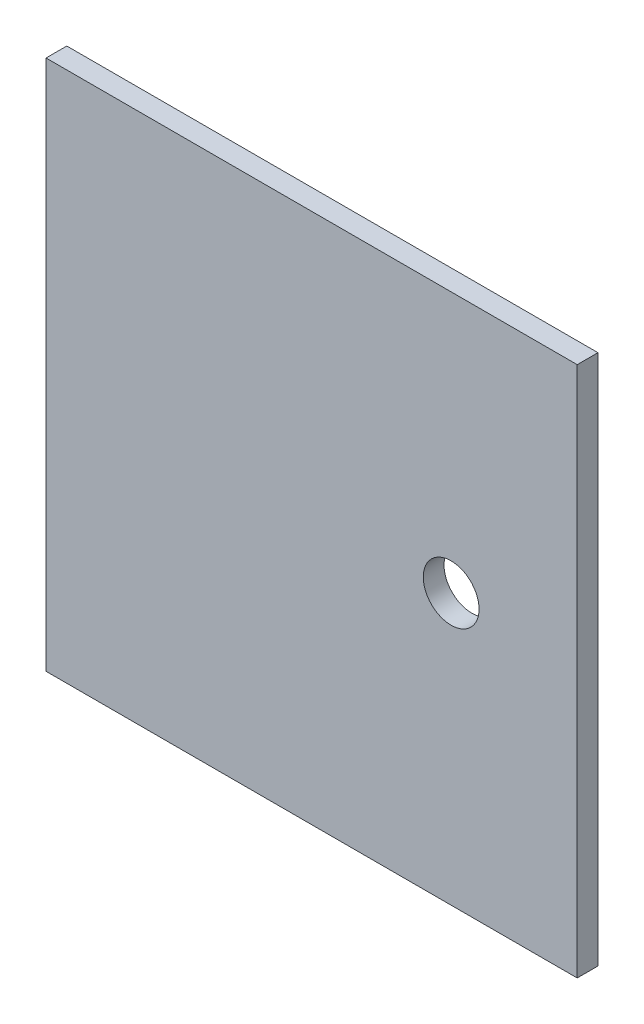
from build123d import *

# Parameters (mm, degrees)
SKETCH1_W           = 80
SKETCH1_H           = 80
BOSS_EXTRUDE1_DEPTH = 3.125
SKETCH2_R           = 4.2
CUT_EXTRUDE1_DEPTH  = 4.125


with BuildPart() as part:
    # Sketch1 → Boss-Extrude1 (new body)
    with BuildSketch(Plane.XY):
        with Locations((40, 40)):
            Rectangle(SKETCH1_W, SKETCH1_H)
    extrude(amount=BOSS_EXTRUDE1_DEPTH)

    # Sketch2 → Cut-Extrude1 (cut, through all)
    with BuildSketch(Plane.XY.offset(3.125)):
        with Locations((61.014742683, 40.7151614)):
            Circle(SKETCH2_R)
    extrude(amount=-CUT_EXTRUDE1_DEPTH, mode=Mode.SUBTRACT)


solid = part.part
